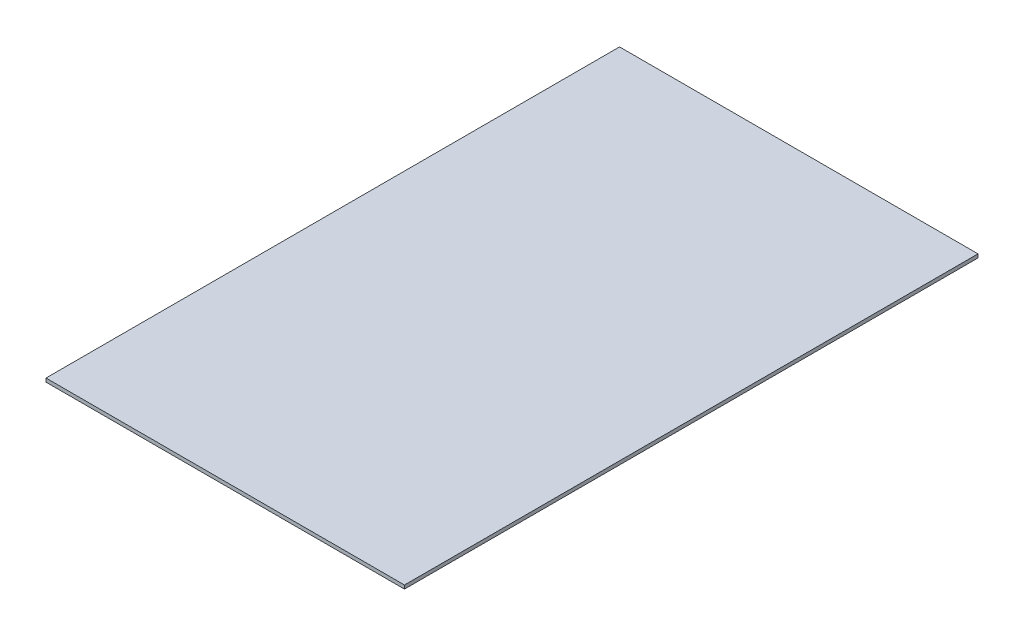
from build123d import *

# Parameters (mm, degrees)
SKETCH_1_W      = 1000
SKETCH_1_H      = 1600
EXTRUDE_1_DEPTH = 10


with BuildPart() as part:
    # 草图1 → 凸台-拉伸1 (new body)
    with BuildSketch(Plane(origin=(0, 0, 0), x_dir=(1, 0, 0), z_dir=(0, 1, 0))):
        with Locations((-1858.108108108, 742.567567568)):
            Rectangle(SKETCH_1_W, SKETCH_1_H)
    extrude(amount=EXTRUDE_1_DEPTH)


solid = part.part
